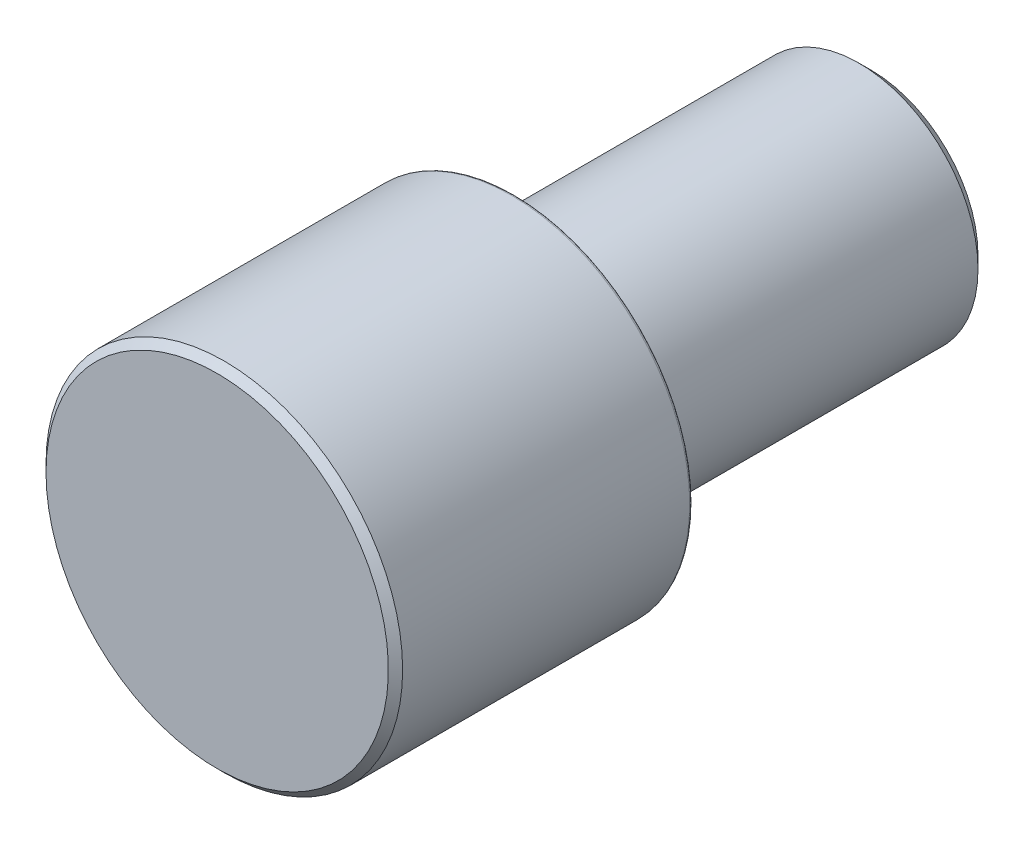
from build123d import *

# Parameters (mm, degrees)
CHAMFER1_SIZE = 0.12
CHAMFER2_SIZE = 0.2


with BuildPart() as part:
    # Sketch1 → Revolve1 (revolve)
    with BuildSketch(Plane(origin=(0, 0, 0), x_dir=(0, 0, -1), z_dir=(1, 0, 0))):
        with BuildLine():
            Line((-5, 0), (-5, 3))
            Line((-5, 3), (-0.05, 3))
            ThreePointArc((-0.05, 3), (-0.014644661, 2.985355339), (0, 2.95))
            Line((0, 2.95), (0, 2.193649167))
            ThreePointArc((0, 2.193649167), (-0.010471529, 2.163030546), (-0.0375, 2.145236875))
            ThreePointArc((-0.0375, 2.145236875), (-0.148804454, 1.981099356), (0, 1.85))
            Line((0, 1.85), (0.3, 1.85))
            Line((0.3, 1.85), (0.3, 2))
            Line((0.3, 2), (6, 2))
            Line((6, 2), (6, 0))
            Line((6, 0), (-5, 0))
        make_face()
    revolve(axis=Axis((0, 0, 12.7), (0, 0, -1)))

    # Chamfer1
    chamfer1_edges = [part.edges().sort_by_distance(p)[0] for p in [
        (0, -3, 5),
    ]]
    chamfer(chamfer1_edges, length=CHAMFER1_SIZE)

    # Chamfer2
    chamfer2_edges = [part.edges().sort_by_distance(p)[0] for p in [
        (0, -2, -6),
    ]]
    chamfer(chamfer2_edges, length=CHAMFER2_SIZE)


solid = part.part
